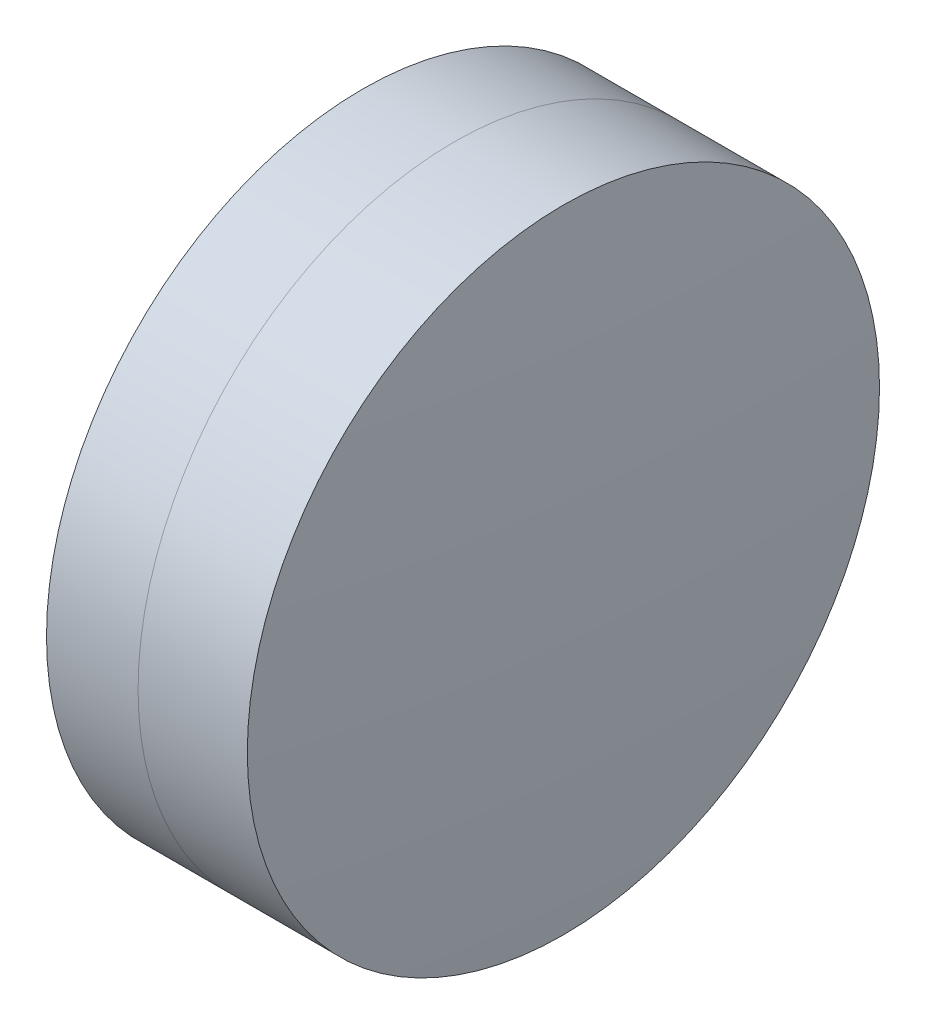
from build123d import *


with BuildPart() as part:
    # 草图1 one side → 旋转1 (revolve)
    with BuildSketch(Plane(origin=(0, 0, 0), x_dir=(1, 0, 0), z_dir=(0, 1, 0)), mode=Mode.PRIVATE) as revolve_1_sk:
        with BuildLine():
            ThreePointArc((4.175781711, 6.35), (3.616945823, 3.196833045), (3.429815177, 0))
            Line((3.429815177, 0), (6.929815177, 0))
            ThreePointArc((6.929815177, 0), (6.699979761, 3.207767043), (6.015169008, 6.35))
            Line((6.015169008, 6.35), (4.175781711, 6.35))
        make_face()
    revolve(revolve_1_sk.sketch.rotate(Axis((-9.702612178, 0, 0), (1, 0, 0)), 180), axis=Axis((-9.702612178, 0, 0), (1, 0, 0)))  # turned: the seam where the file's is


with BuildPart() as body_2:
    # 草图2 one side → 旋转3 (revolve)
    with BuildSketch(Plane(origin=(0, 0, 0), x_dir=(1, 0, 0), z_dir=(0, 1, 0)), mode=Mode.PRIVATE) as revolve_3_sk:
        with BuildLine():
            Line((8.209930377, 6.35), (6.015169008, 6.35))
            ThreePointArc((6.015169008, 6.35), (6.699979761, 3.207767043), (6.929815177, 0))
            Line((6.929815177, 0), (8.429815177, 0))
            ThreePointArc((8.429815177, 0), (8.374827508, 3.176902946), (8.209930377, 6.35))
        make_face()
    revolve(revolve_3_sk.sketch.rotate(Axis((-0.551919993, 0, 0), (1, 0, 0)), 180), axis=Axis((-0.551919993, 0, 0), (1, 0, 0)))  # turned: the seam where the file's is


solid = Compound([part.part, body_2.part])
